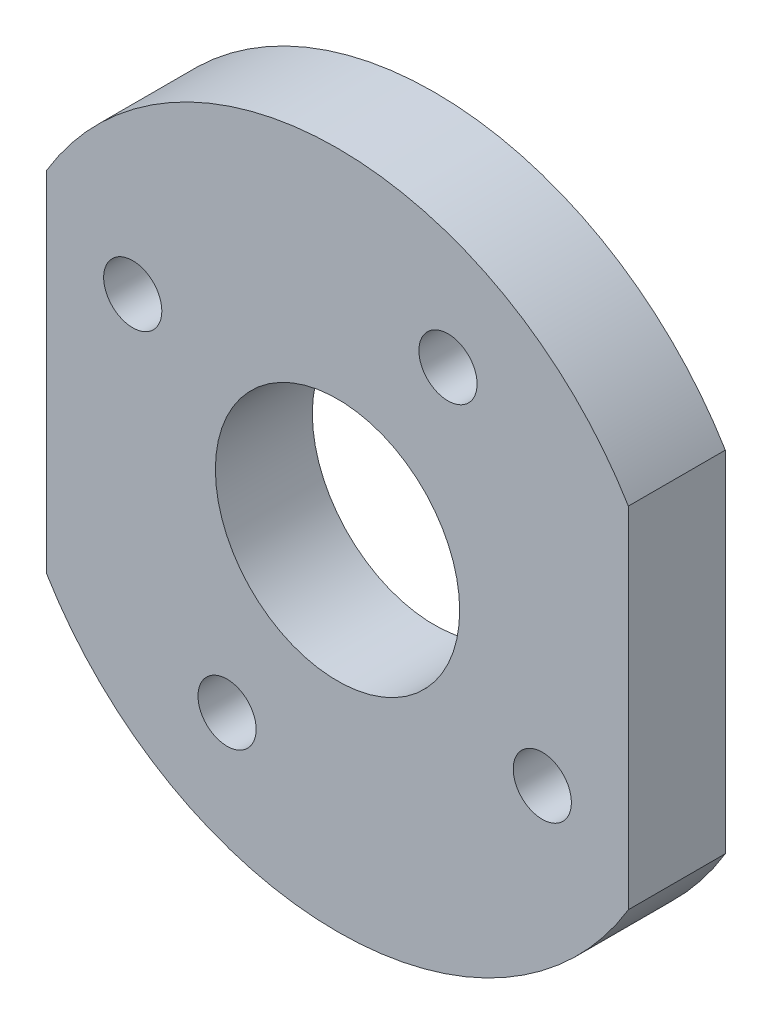
from build123d import *

# Parameters (mm, degrees)
SKETCH2_R           = 6.3
SKETCH2_R_2         = 1.5
BOSS_EXTRUDE1_DEPTH = 5


with BuildPart() as part:
    # Sketch2 → Boss-Extrude1 (new body)
    with BuildSketch(Plane.XY):
        with BuildLine():
            Line((-3.65491696, 65.036481871), (-3.65491696, 47.008725494))
            ThreePointArc((-3.65491696, 47.008725494), (11.34508304, 38.522603682), (26.34508304, 47.008725494))
            Line((26.34508304, 47.008725494), (26.34508304, 65.036481871))
            ThreePointArc((26.34508304, 65.036481871), (11.34508304, 73.522603682), (-3.65491696, 65.036481871))
        make_face()
        with Locations((11.34508304, 56.022603682)):
            Circle(SKETCH2_R, mode=Mode.SUBTRACT)
        with Locations((17.04239712, 66.583882595)):
            Circle(SKETCH2_R_2, mode=Mode.SUBTRACT)
        with Locations((5.64776896, 45.46132477)):
            Circle(SKETCH2_R_2, mode=Mode.SUBTRACT)
        with Locations((0.783804127, 61.719917763)):
            Circle(SKETCH2_R_2, mode=Mode.SUBTRACT)
        with Locations((21.906361952, 50.325289602)):
            Circle(SKETCH2_R_2, mode=Mode.SUBTRACT)
    extrude(amount=BOSS_EXTRUDE1_DEPTH)


solid = part.part
